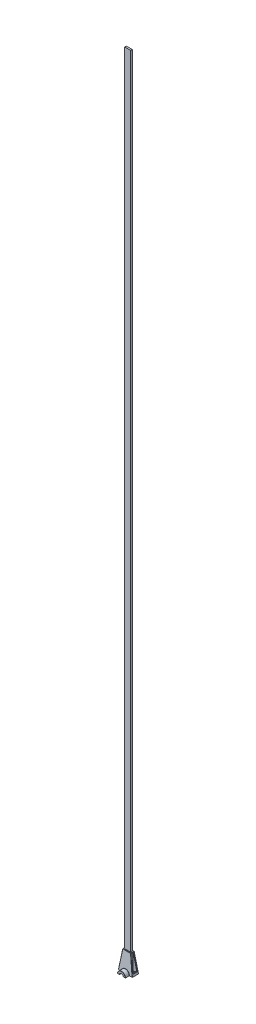
from build123d import *

# Parameters (mm, degrees)
CYLINDRE_DEPTH         = 50
ESQUISSE_BASE_W        = 70
ESQUISSE_BASE_H        = 32
ESQUISSE_EXTR_MIT_W    = 40
ESQUISSE_EXTR_MIT_H    = 18
ESQUISSE_BARRE_W       = 30
ESQUISSE_BARRE_H       = 8
BARRE_DEPTH            = 3905
LOGEMENT_REACH         = 3990.467
CONG_S_R1_R            = 1
ESQUISSE_AL_SAGE_R     = 10
AL_SAGE_DEPTH          = 49
ESQUISSE_FRAISAGE_W    = 72
ESQUISSE_FRAISAGE_H    = 2
FRAISAGE_DEPTH         = 4001.484626894
ESQUISSE_TROUS_R       = 3.5
TROUS_DEPTH            = 4000.464335672
RAINURE_CLAVETTE_DEPTH = 13.5


with BuildPart() as part:
    # Esquisse cylindre → Cylindre (new body)
    with BuildSketch(Plane.XY):
        with BuildLine():
            Line((-20, 0), (20, 0))
            ThreePointArc((20, 0), (0, 20), (-20, 0))
        make_face()
    extrude(amount=CYLINDRE_DEPTH)

    # Esquisse base → Forme moulée section 0
    with BuildSketch(Plane.XZ):
        with Locations((0, 14.5)):
            Rectangle(ESQUISSE_BASE_W, ESQUISSE_BASE_H)
    # Esquisse extrémité → Forme moulée section 1
    with BuildSketch(Plane(origin=(0, 95, 0), x_dir=(-1, 0, 0), z_dir=(0, 1, 0))):
        with Locations((0, 14.5)):
            Rectangle(ESQUISSE_EXTR_MIT_W, ESQUISSE_EXTR_MIT_H)
    loft()

    # Esquisse barre → Barre (add)
    with BuildSketch(Plane(origin=(0, 95, 0), x_dir=(-1, 0, 0), z_dir=(0, 1, 0))):
        with Locations((0, 14.5)):
            Rectangle(ESQUISSE_BARRE_W, ESQUISSE_BARRE_H)
    extrude(amount=BARRE_DEPTH)

    # Esquisse logement → Logement (cut, up to next)
    with BuildSketch(Plane(origin=(0, 12, 0), x_dir=(-1, 0, 0), z_dir=(0, 1, 0)), mode=Mode.PRIVATE) as logement_sk1:
        Polygon((-20.2, 18), (-20.2, 11), (-35, 4), (-35, 25), align=None)
    logement_tool1 = extrude(logement_sk1.sketch, amount=LOGEMENT_REACH, mode=Mode.PRIVATE) & part.part
    logement = logement_tool1.solids().sort_by_distance((28.833333, 12, 14.5))[0]
    add(logement, mode=Mode.SUBTRACT)

    # Symétrie logement: Logement across plane
    add(logement.mirror(Plane(origin=(0, 0, 0), x_dir=(0, 0, 1), z_dir=(1, 0, 0))), mode=Mode.SUBTRACT)

    # Congés R1
    cong_s_r1_edges = [part.edges().sort_by_distance(p)[0] for p in [
        (27.5, 47.5, 2),
        (27.5, 47.5, 27),
        (20, 95, 14.5),
        (26.652631579, 52.866666667, 7.948079659),
        (33.105263158, 12, 14.5),
        (26.652631579, 52.866666667, 21.051920341),
        (0, 95, 5.5),
        (-27.5, 47.5, 2),
        (-27.5, 47.5, 27),
        (-20, 95, 14.5),
        (-26.652631579, 52.866666667, 21.051920341),
        (-33.105263158, 12, 14.5),
        (-26.652631579, 52.866666667, 7.948079659),
        (0, 95, 23.5),
        (0, 20, 29.026315789),
        (0, 20, 50),
    ]]
    fillet(cong_s_r1_edges, radius=CONG_S_R1_R)

    # Esquisse alésage → Alésage (cut)
    with BuildSketch(Plane.XY.offset(50)):
        Circle(ESQUISSE_AL_SAGE_R)
    extrude(amount=-AL_SAGE_DEPTH, mode=Mode.SUBTRACT)

    # Esquisse fraisage → Fraisage (cut, through all)
    with BuildSketch(Plane.XY.offset(50)):
        Rectangle(ESQUISSE_FRAISAGE_W, ESQUISSE_FRAISAGE_H)
    extrude(amount=-FRAISAGE_DEPTH, mode=Mode.SUBTRACT)

    # Esquisse trous → Trous (cut, through all)
    with BuildSketch(Plane.XZ.offset(-1)):
        with Locations(Location((25.5, 14.573684211, 0), (0, 0, 270))):
            Circle(ESQUISSE_TROUS_R)
        with Locations(Location((-25.5, 14.573684211, 0), (0, 0, 270))):
            Circle(ESQUISSE_TROUS_R)
    extrude(amount=-TROUS_DEPTH, mode=Mode.SUBTRACT)

    # Esquisse rainure → Rainure clavette (cut)
    with BuildSketch(Plane.XZ.offset(-1)):
        with BuildLine():
            Line((3, 42), (3, 4))
            ThreePointArc((3, 4), (0, 1), (-3, 4))
            Line((-3, 4), (-3, 42))
            ThreePointArc((-3, 42), (0, 45), (3, 42))
        make_face()
    extrude(amount=-RAINURE_CLAVETTE_DEPTH, mode=Mode.SUBTRACT)


solid = part.part
